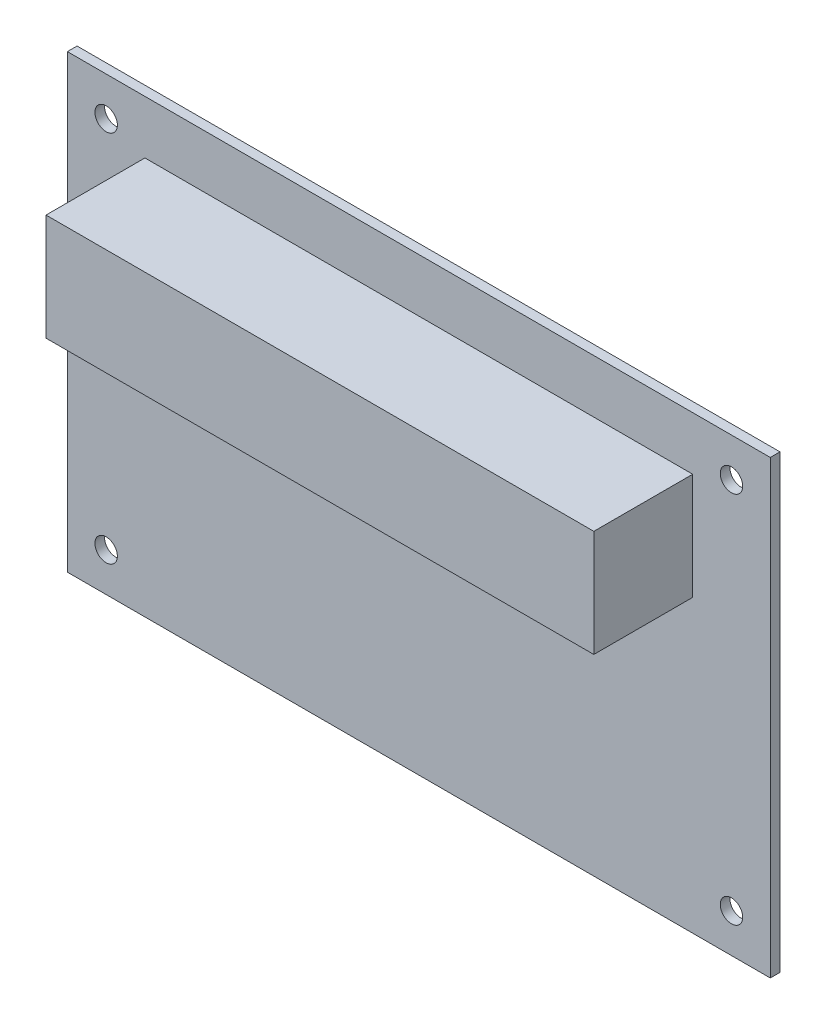
from build123d import *

# Parameters (mm, degrees)
ESQUISSE1_W        = 72.5
ESQUISSE1_H        = 46.5
ESQUISSE1_R        = 1.16
BOSS_EXTRU_1_DEPTH = 1
ESQUISSE2_W        = 56.5
ESQUISSE2_H        = 11
BOSS_EXTRU_3_DEPTH = 10.2


with BuildPart() as part:
    # Esquisse1 → Boss.-Extru.1 (new body)
    with BuildSketch(Plane(origin=(-4.272208628, 0, 0), x_dir=(1, 0, 0), z_dir=(0, 0, 1))):
        with Locations((36.25, 23.25)):
            Rectangle(ESQUISSE1_W, ESQUISSE1_H)
        with Locations((4, 42.5)):
            Circle(ESQUISSE1_R, mode=Mode.SUBTRACT)
        with Locations((68.5, 42.5)):
            Circle(ESQUISSE1_R, mode=Mode.SUBTRACT)
        with Locations((68.5, 4)):
            Circle(ESQUISSE1_R, mode=Mode.SUBTRACT)
        with Locations((4, 4)):
            Circle(ESQUISSE1_R, mode=Mode.SUBTRACT)
    extrude(amount=BOSS_EXTRU_1_DEPTH)

    # Esquisse2 → Boss.-Extru.3 (add)
    with BuildSketch(Plane(origin=(-4.272208628, 0, 1), x_dir=(1, 0, 0), z_dir=(0, 0, 1))):
        with Locations((36.25, 35.5)):
            Rectangle(ESQUISSE2_W, ESQUISSE2_H)
    extrude(amount=BOSS_EXTRU_3_DEPTH)


solid = part.part
